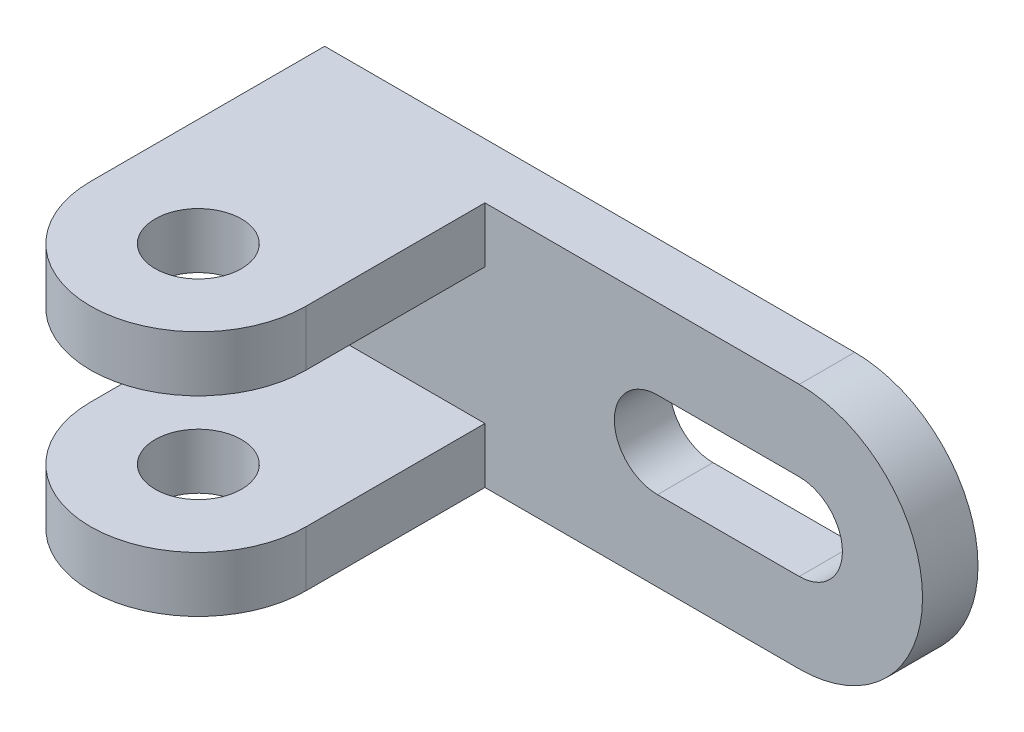
from build123d import *

# Parameters (mm, degrees)
BOSS_EXTRUDE1_DEPTH = 9
SKETCH3_R           = 17.5
SKETCH3_R_2         = 7
SKETCH3_W           = 35
SKETCH3_H           = 9
BOSS_EXTRUDE2_DEPTH = 9


with BuildPart() as part:
    # Sketch1 → Boss-Extrude1 (new body)
    with BuildSketch(Plane.XY):
        with BuildLine():
            Line((0, -20), (86, -20))
            ThreePointArc((86, -20), (106, 0), (86, 20))
            Line((86, 20), (0, 20))
            Line((0, 20), (0, -20))
        make_face()
        with BuildLine():
            Line((63, 7), (86, 7))
            ThreePointArc((86, 7), (93, 0), (86, -7))
            Line((86, -7), (63, -7))
            ThreePointArc((63, -7), (56, 0), (63, 7))
        make_face(mode=Mode.SUBTRACT)
    extrude(amount=BOSS_EXTRUDE1_DEPTH)

    # Sketch3 → Boss-Extrude2 (add)
    with BuildSketch(Plane.XZ.offset(20)):
        with BuildLine():
            Line((0, 38), (0, 9))
            Line((0, 9), (35, 9))
            Line((35, 9), (35, 38))
            ThreePointArc((35, 38), (17.5, 20.5), (0, 38))
        make_face()
        with Locations((17.5, 38)):
            Circle(SKETCH3_R)
        with Locations((17.5, 38)):
            Circle(SKETCH3_R_2, mode=Mode.SUBTRACT)
        with Locations((17.5, 4.5)):
            Rectangle(SKETCH3_W, SKETCH3_H)
    boss_extrude2 = extrude(amount=-BOSS_EXTRUDE2_DEPTH)

    # Mirror1: Boss-Extrude2 across plane
    add(boss_extrude2.mirror(Plane.ZX))


solid = part.part
